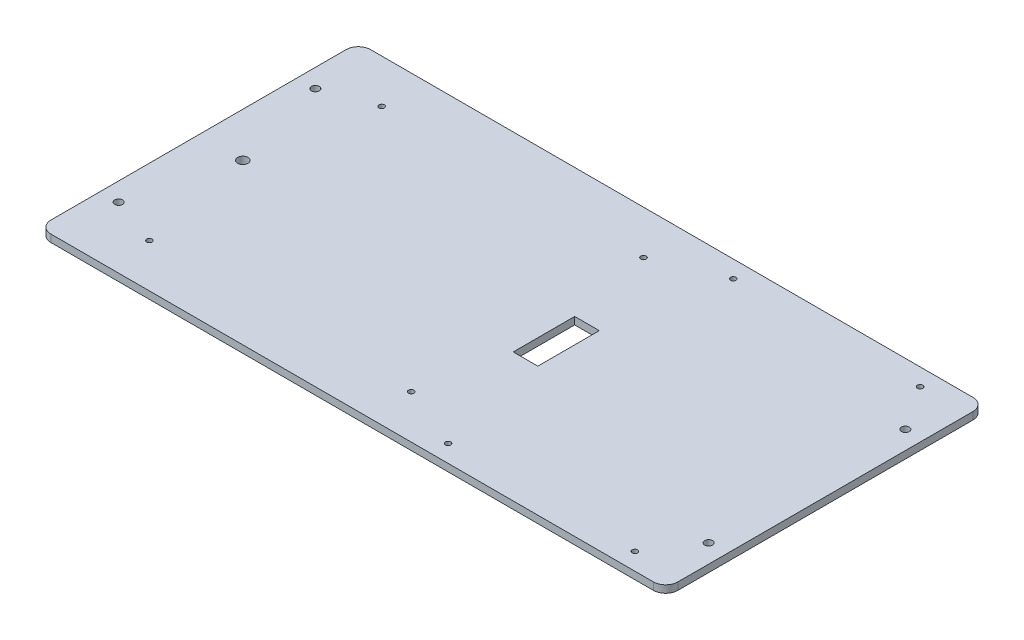
from build123d import *

# Parameters (mm, degrees)
SKETCH1_W           = 255
SKETCH1_H           = 130
SKETCH1_R           = 1.6
SKETCH1_R_2         = 1.1
SKETCH1_R_3         = 2.1
SKETCH1_W_2         = 10
SKETCH1_H_2         = 25
BOSS_EXTRUDE1_DEPTH = 3
FILLET1_R           = 5


with BuildPart() as part:
    # Sketch1 → Boss-Extrude1 (new body)
    with BuildSketch(Plane(origin=(0, 0, 0), x_dir=(1, 0, 0), z_dir=(0, 1, 0))):
        Rectangle(SKETCH1_W, SKETCH1_H)
        with Locations((120, -40)):
            Circle(SKETCH1_R, mode=Mode.SUBTRACT)
        with Locations((-120, -40)):
            Circle(SKETCH1_R, mode=Mode.SUBTRACT)
        with Locations((120, 40)):
            Circle(SKETCH1_R, mode=Mode.SUBTRACT)
        with Locations((-120, 40)):
            Circle(SKETCH1_R, mode=Mode.SUBTRACT)
        with Locations((32, -58)):
            Circle(SKETCH1_R_2, mode=Mode.SUBTRACT)
        with Locations((108, -58)):
            Circle(SKETCH1_R_2, mode=Mode.SUBTRACT)
        with Locations((108, 58)):
            Circle(SKETCH1_R_2, mode=Mode.SUBTRACT)
        with Locations((32, 58)):
            Circle(SKETCH1_R_2, mode=Mode.SUBTRACT)
        with Locations((-100.25, 47.25)):
            Circle(SKETCH1_R_2, mode=Mode.SUBTRACT)
        with Locations((6.25, 47.25)):
            Circle(SKETCH1_R_2, mode=Mode.SUBTRACT)
        with Locations((-100.25, -47.25)):
            Circle(SKETCH1_R_2, mode=Mode.SUBTRACT)
        with Locations((6.25, -47.25)):
            Circle(SKETCH1_R_2, mode=Mode.SUBTRACT)
        with Locations((-109.5, 0)):
            Circle(SKETCH1_R_3, mode=Mode.SUBTRACT)
        with Locations((18, 0)):
            Rectangle(SKETCH1_W_2, SKETCH1_H_2, mode=Mode.SUBTRACT)
    extrude(amount=BOSS_EXTRUDE1_DEPTH)

    # Fillet1
    fillet1_edges = [part.edges().sort_by_distance(p)[0] for p in [
        (127.5, 1.5, 65),
        (-127.5, 1.5, 65),
        (-127.5, 1.5, -65),
        (127.5, 1.5, -65),
    ]]
    fillet(fillet1_edges, radius=FILLET1_R)


solid = part.part
